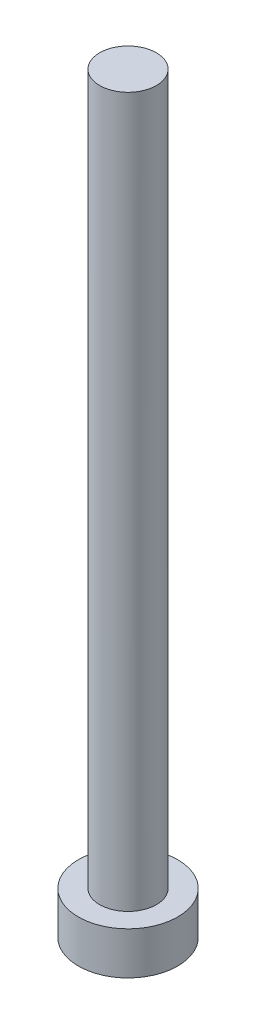
from build123d import *

# Parameters (mm, degrees)
SKETCH1_R           = 2
BOSS_EXTRUDE1_DEPTH = 50
SKETCH2_R           = 3.5
BOSS_EXTRUDE2_DEPTH = 3


with BuildPart() as part:
    # Sketch1 → Boss-Extrude1 (new body)
    with BuildSketch(Plane(origin=(0, 0, 0), x_dir=(1, 0, 0), z_dir=(0, 1, 0))):
        Circle(SKETCH1_R)
    extrude(amount=BOSS_EXTRUDE1_DEPTH)

    # Sketch2 → Boss-Extrude2 (add)
    with BuildSketch(Plane.XZ):
        Circle(SKETCH2_R)
    extrude(amount=BOSS_EXTRUDE2_DEPTH)


solid = part.part
